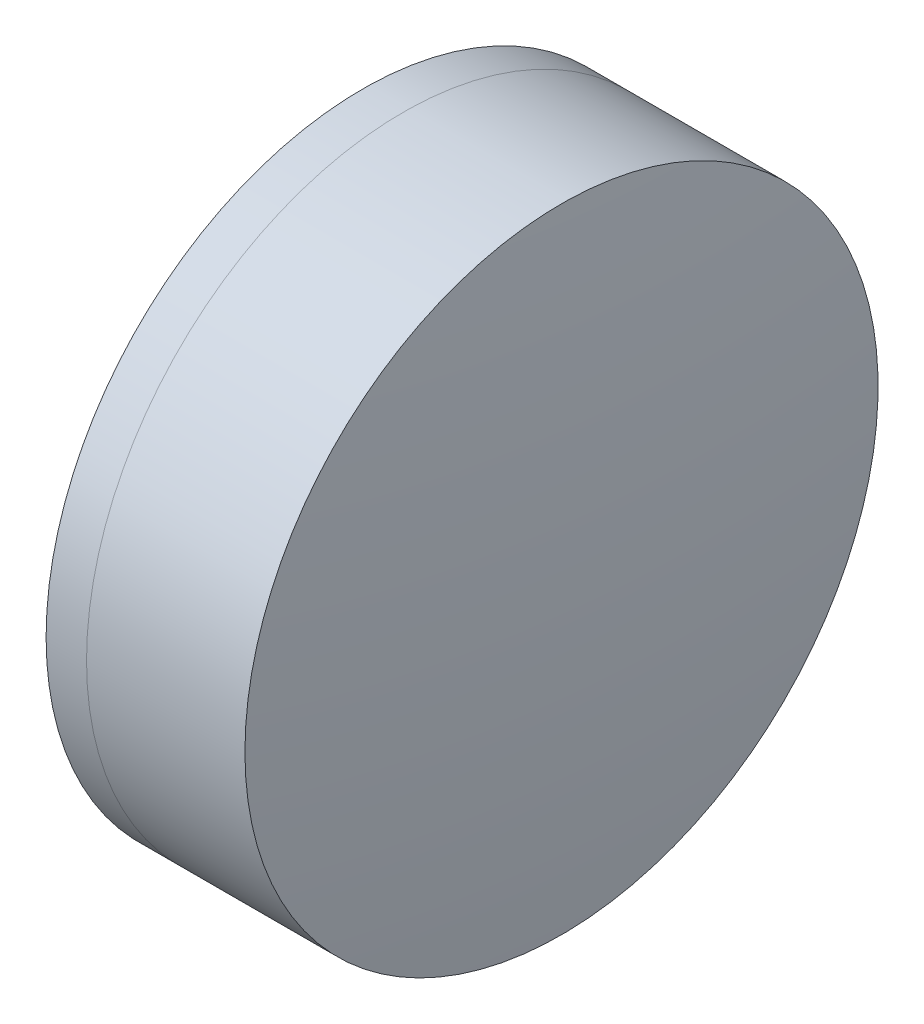
from build123d import *


with BuildPart() as part:
    # 草图1 one side → 旋转1 (revolve)
    with BuildSketch(Plane(origin=(0, 0, 0), x_dir=(1, 0, 0), z_dir=(0, 1, 0)), mode=Mode.PRIVATE) as revolve_1_sk:
        with BuildLine():
            ThreePointArc((-0.951039891, 6.35), (-2.197394506, 3.283107471), (-2.622170847, 0))
            Line((-2.622170847, 0), (1.877829153, 0))
            ThreePointArc((1.877829153, 0), (1.361214105, 3.331462134), (-0.140105383, 6.35))
            Line((-0.140105383, 6.35), (-0.951039891, 6.35))
        make_face()
    revolve(revolve_1_sk.sketch.rotate(Axis((-9.702612178, 0, 0), (1, 0, 0)), 180), axis=Axis((-9.702612178, 0, 0), (1, 0, 0)))  # turned: the seam where the file's is


with BuildPart() as body_2:
    # 草图2 one side → 旋转3 (revolve)
    with BuildSketch(Plane(origin=(0, 0, 0), x_dir=(1, 0, 0), z_dir=(0, 1, 0)), mode=Mode.PRIVATE) as revolve_3_sk:
        with BuildLine():
            Line((3.03686154, 6.35), (-0.140105383, 6.35))
            ThreePointArc((-0.140105383, 6.35), (1.361214105, 3.331462134), (1.877829153, 0))
            Line((1.877829153, 0), (3.377829153, 0))
            ThreePointArc((3.377829153, 0), (3.292525895, 3.179573828), (3.03686154, 6.35))
        make_face()
    revolve(revolve_3_sk.sketch.rotate(Axis((-0.551919993, 0, 0), (1, 0, 0)), 180), axis=Axis((-0.551919993, 0, 0), (1, 0, 0)))  # turned: the seam where the file's is


solid = Compound([part.part, body_2.part])
